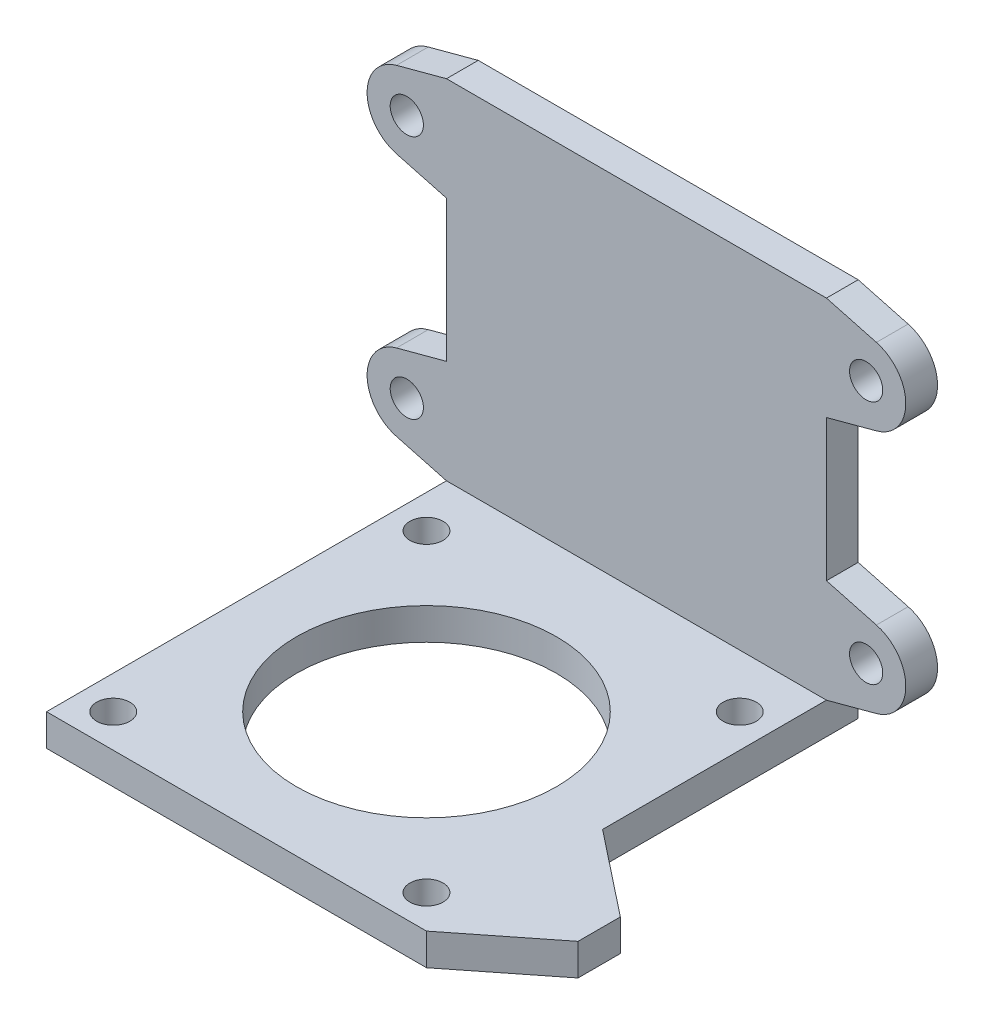
from build123d import *

# Parameters (mm, degrees)
SKETCH1_W              = 57
SKETCH1_H              = 57
BOSS_EXTRUDE1_DEPTH    = 4.7625
SKETCH2_W              = 57
SKETCH2_H              = 4.7625
BOSS_EXTRUDE2_DEPTH    = 60
SKETCH3_R              = 19.5
CUT_EXTRUDE1_DEPTH     = 5.7625
F_10_CLEARANCE_HOLE1_D = 4.9784
BOSS_EXTRUDE3_DEPTH    = 4.7625
F_10_CLEARANCE_HOLE2_D = 4.9784
BOSS_EXTRUDE4_DEPTH    = 4.7625


with BuildPart() as part:
    # Sketch1 → Boss-Extrude1 (new body)
    with BuildSketch(Plane.XY):
        Rectangle(SKETCH1_W, SKETCH1_H)
    extrude(amount=BOSS_EXTRUDE1_DEPTH)

    # Sketch2 → Boss-Extrude2 (add)
    with BuildSketch(Plane.XY.offset(4.7625)):
        with Locations((0, -26.11875)):
            Rectangle(SKETCH2_W, SKETCH2_H)
    extrude(amount=BOSS_EXTRUDE2_DEPTH)

    # Sketch3 → Cut-Extrude1 (cut, through all)
    with BuildSketch(Plane(origin=(0, -23.7375, 0), x_dir=(1, 0, 0), z_dir=(0, 1, 0))):
        with Locations((0, -36.2625)):
            Circle(SKETCH3_R)
    extrude(amount=-CUT_EXTRUDE1_DEPTH, mode=Mode.SUBTRACT)

    # #10 Clearance Hole1 (through all)
    with Locations(Plane(origin=(0, -28.5, 0), x_dir=(-1, 0, 0), z_dir=(0, -1, 0))):
        with Locations((0, -36.2625), (-23.495, -12.7675), (23.495, -59.7575), (23.495, -12.7675), (-23.495, -59.7575)):
            Hole(F_10_CLEARANCE_HOLE1_D / 2)

    # Sketch7 → Boss-Extrude3 (add)
    with BuildSketch(Plane.XY):
        with BuildLine():
            Line((28.5, -23.7375), (35.993907128, -21.729513637))
            ThreePointArc((35.993907128, -21.729513637), (40.40625, -15.979236452), (35.993907128, -10.228959268))
            Line((35.993907128, -10.228959268), (28.5, -8.220972905))
            Line((28.5, -8.220972905), (28.5, -23.7375))
        make_face()
        with BuildLine():
            Line((28.5, 12.983472905), (35.993907128, 14.991459268))
            ThreePointArc((35.993907128, 14.991459268), (40.40625, 20.741736452), (35.993907128, 26.492013637))
            Line((35.993907128, 26.492013637), (28.5, 28.5))
            Line((28.5, 28.5), (28.5, 12.983472905))
        make_face()
        with BuildLine():
            Line((-28.5, 28.5), (-28.5, 12.983472905))
            Line((-28.5, 12.983472905), (-35.993907128, 14.991459268))
            ThreePointArc((-35.993907128, 14.991459268), (-40.40625, 20.741736452), (-35.993907128, 26.492013637))
            Line((-35.993907128, 26.492013637), (-28.5, 28.5))
        make_face()
        with BuildLine():
            Line((-28.5, -23.7375), (-35.993907128, -21.729513637))
            ThreePointArc((-35.993907128, -21.729513637), (-40.40625, -15.979236452), (-35.993907128, -10.228959268))
            Line((-35.993907128, -10.228959268), (-28.5, -8.220972905))
            Line((-28.5, -8.220972905), (-28.5, -23.7375))
        make_face()
    extrude(amount=BOSS_EXTRUDE3_DEPTH)

    # #10 Clearance Hole2 (through all)
    with Locations(Plane.XY.offset(4.7625)):
        with Locations((34.453125, -15.979236452), (34.453125, 20.741736452), (-34.453125, 20.741736452), (-34.453125, -15.979236452)):
            Hole(F_10_CLEARANCE_HOLE2_D / 2)

    # Sketch10 → Boss-Extrude4 (add)
    with BuildSketch(Plane.XZ.offset(28.5)):
        Polygon((41.2, 48.3795), (41.2, 54.7295), (28.5, 64.7625), (28.5, 38.3465), align=None)
    extrude(amount=-BOSS_EXTRUDE4_DEPTH)


solid = part.part
